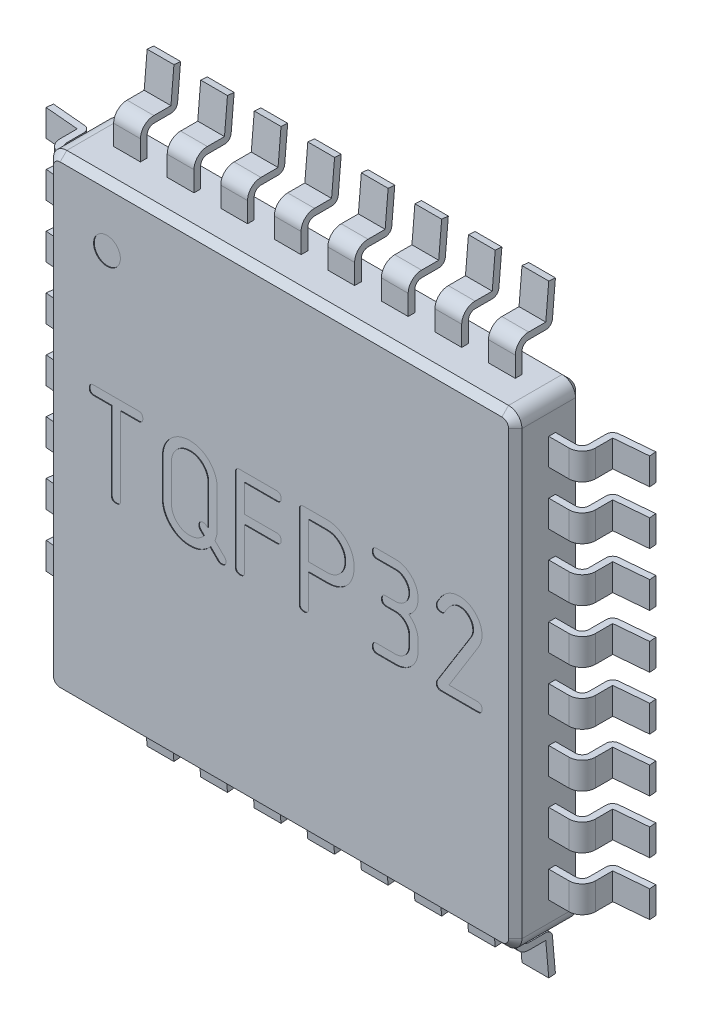
from build123d import *

# Parameters (mm, degrees)
EXTRUDE_1_DEPTH                  = 1
CHAMFER_1_SIZE                   = 0.1
EXTRUDE_2_DEPTH                  = 0.2
PATTERN_LINEAR_1_COUNT           = 8
PATTERN_LINEAR_1_PITCH           = 0.8
PATTERN_CIRCULAR_1_COUNT         = 4
PATTERN_CIRCULAR_1_COPY_1_DEPTH  = 0.2
PATTERN_CIRCULAR_1_COPY_2_DEPTH  = 0.2
PATTERN_CIRCULAR_1_COPY_3_DEPTH  = 0.2
PATTERN_CIRCULAR_1_COPY_4_DEPTH  = 0.2
PATTERN_CIRCULAR_1_COPY_5_DEPTH  = 0.2
PATTERN_CIRCULAR_1_COPY_6_DEPTH  = 0.2
PATTERN_CIRCULAR_1_COPY_7_DEPTH  = 0.2
PATTERN_CIRCULAR_1_COPY_8_DEPTH  = 0.2
PATTERN_CIRCULAR_1_COPY_9_DEPTH  = 0.2
PATTERN_CIRCULAR_1_COPY_10_DEPTH = 0.2
PATTERN_CIRCULAR_1_COPY_11_DEPTH = 0.2
PATTERN_CIRCULAR_1_COPY_12_DEPTH = 0.2
PATTERN_CIRCULAR_1_COPY_13_DEPTH = 0.2
PATTERN_CIRCULAR_1_COPY_14_DEPTH = 0.2
PATTERN_CIRCULAR_1_COPY_15_DEPTH = 0.2
PATTERN_CIRCULAR_1_COPY_16_DEPTH = 0.2
PATTERN_CIRCULAR_1_COPY_17_DEPTH = 0.2
PATTERN_CIRCULAR_1_COPY_18_DEPTH = 0.2
PATTERN_CIRCULAR_1_COPY_19_DEPTH = 0.2
PATTERN_CIRCULAR_1_COPY_20_DEPTH = 0.2
PATTERN_CIRCULAR_1_COPY_21_DEPTH = 0.2
SKETCH_4_R                       = 0.2
CUT_EXTRUDE_1_DEPTH              = 0.01


with BuildPart() as part:
    # Эскиз2 → Бобышка-Вытянуть1 (new body)
    with BuildSketch(Plane.XY.offset(0.1)):
        with BuildLine():
            Line((-3.3, 3.5), (3.3, 3.5))
            ThreePointArc((3.3, 3.5), (3.441421356, 3.441421356), (3.5, 3.3))
            Line((3.5, 3.3), (3.5, -3.3))
            ThreePointArc((3.5, -3.3), (3.441421356, -3.441421356), (3.3, -3.5))
            Line((3.3, -3.5), (-3.3, -3.5))
            ThreePointArc((-3.3, -3.5), (-3.441421356, -3.441421356), (-3.5, -3.3))
            Line((-3.5, -3.3), (-3.5, 3.3))
            ThreePointArc((-3.5, 3.3), (-3.441421356, 3.441421356), (-3.3, 3.5))
        make_face()
    extrude(amount=EXTRUDE_1_DEPTH)

    # Фаска1
    chamfer_1_edges = [part.edges().sort_by_distance(p)[0] for p in [
        (0, 3.5, 0.1),
        (-3.441421356, 3.441421356, 0.1),
        (3.441421356, 3.441421356, 0.1),
        (-3.5, 0, 0.1),
        (3.5, 0, 0.1),
        (-3.441421356, -3.441421356, 0.1),
        (3.441421356, -3.441421356, 0.1),
        (0, -3.5, 0.1),
        (0, 3.5, 1.1),
        (-3.441421356, 3.441421356, 1.1),
        (3.441421356, 3.441421356, 1.1),
        (-3.5, 0, 1.1),
        (3.5, 0, 1.1),
        (-3.441421356, -3.441421356, 1.1),
        (3.441421356, -3.441421356, 1.1),
        (0, -3.5, 1.1),
    ]]
    chamfer(chamfer_1_edges, length=CHAMFER_1_SIZE)

    # Эскиз3 → Бобышка-Вытянуть2 (add, symmetric)
    with BuildSketch(Plane(origin=(0, 2.8, 0), x_dir=(-1, 0, 0), z_dir=(0, 1, 0))):
        with BuildLine():
            Line((3.5, 0.5), (3.8, 0.5))
            ThreePointArc((3.8, 0.5), (3.870710678, 0.470710678), (3.9, 0.4))
            Line((3.9, 0.4), (3.9, 0.144126316))
            ThreePointArc((3.9, 0.144126316), (3.926272266, 0.076567295), (3.991284426, 0.044506846))
            Line((3.991284426, 0.044506846), (4.5, 0))
            Line((4.5, 0), (4.508715574, 0.09961947))
            Line((4.508715574, 0.09961947), (4, 0.144126316))
            Line((4, 0.144126316), (4, 0.4))
            ThreePointArc((4, 0.4), (3.941421356, 0.541421356), (3.8, 0.6))
            Line((3.8, 0.6), (3.5, 0.6))
            Line((3.5, 0.6), (3.5, 0.5))
        make_face()
    extrude_2 = extrude(amount=EXTRUDE_2_DEPTH, both=True)

    # Линейный массив1: Бобышка-Вытянуть2 ×8
    with Locations(*[(0, -i * PATTERN_LINEAR_1_PITCH, 0) for i in range(1, PATTERN_LINEAR_1_COUNT)]):
        add(extrude_2)

    # Круговой массив1: Бобышка-Вытянуть2 ×4 about axis
    pattern_circular_1_axis = Axis((0, 0, -0.055), (0, 0, 1))
    for i in range(1, PATTERN_CIRCULAR_1_COUNT):
        add(extrude_2.rotate(pattern_circular_1_axis, i * 360 / PATTERN_CIRCULAR_1_COUNT))

    # Круговой массив1 copy 1 sketch → Круговой массив1 copy 1 (add, symmetric)
    with BuildSketch(Plane(origin=(-2, 0, 0), x_dir=(0, -1, 0), z_dir=(-1, 0, 0))):
        with BuildLine():
            Line((3.5, 0.5), (3.8, 0.5))
            ThreePointArc((3.8, 0.5), (3.870710678, 0.470710678), (3.9, 0.4))
            Line((3.9, 0.4), (3.9, 0.144126316))
            ThreePointArc((3.9, 0.144126316), (3.926272266, 0.076567295), (3.991284426, 0.044506846))
            Line((3.991284426, 0.044506846), (4.5, 0))
            Line((4.5, 0), (4.508715574, 0.09961947))
            Line((4.508715574, 0.09961947), (4, 0.144126316))
            Line((4, 0.144126316), (4, 0.4))
            ThreePointArc((4, 0.4), (3.941421356, 0.541421356), (3.8, 0.6))
            Line((3.8, 0.6), (3.5, 0.6))
            Line((3.5, 0.6), (3.5, 0.5))
        make_face()
    extrude(amount=PATTERN_CIRCULAR_1_COPY_1_DEPTH, both=True)

    # Круговой массив1 copy 2 sketch → Круговой массив1 copy 2 (add, symmetric)
    with BuildSketch(Plane.XZ.offset(2)):
        with BuildLine():
            Line((3.5, 0.5), (3.8, 0.5))
            ThreePointArc((3.8, 0.5), (3.870710678, 0.470710678), (3.9, 0.4))
            Line((3.9, 0.4), (3.9, 0.144126316))
            ThreePointArc((3.9, 0.144126316), (3.926272266, 0.076567295), (3.991284426, 0.044506846))
            Line((3.991284426, 0.044506846), (4.5, 0))
            Line((4.5, 0), (4.508715574, 0.09961947))
            Line((4.508715574, 0.09961947), (4, 0.144126316))
            Line((4, 0.144126316), (4, 0.4))
            ThreePointArc((4, 0.4), (3.941421356, 0.541421356), (3.8, 0.6))
            Line((3.8, 0.6), (3.5, 0.6))
            Line((3.5, 0.6), (3.5, 0.5))
        make_face()
    extrude(amount=PATTERN_CIRCULAR_1_COPY_2_DEPTH, both=True)

    # Круговой массив1 copy 3 sketch → Круговой массив1 copy 3 (add, symmetric)
    with BuildSketch(Plane.YZ.offset(2)):
        with BuildLine():
            Line((3.5, 0.5), (3.8, 0.5))
            ThreePointArc((3.8, 0.5), (3.870710678, 0.470710678), (3.9, 0.4))
            Line((3.9, 0.4), (3.9, 0.144126316))
            ThreePointArc((3.9, 0.144126316), (3.926272266, 0.076567295), (3.991284426, 0.044506846))
            Line((3.991284426, 0.044506846), (4.5, 0))
            Line((4.5, 0), (4.508715574, 0.09961947))
            Line((4.508715574, 0.09961947), (4, 0.144126316))
            Line((4, 0.144126316), (4, 0.4))
            ThreePointArc((4, 0.4), (3.941421356, 0.541421356), (3.8, 0.6))
            Line((3.8, 0.6), (3.5, 0.6))
            Line((3.5, 0.6), (3.5, 0.5))
        make_face()
    extrude(amount=PATTERN_CIRCULAR_1_COPY_3_DEPTH, both=True)

    # Круговой массив1 copy 4 sketch → Круговой массив1 copy 4 (add, symmetric)
    with BuildSketch(Plane(origin=(-1.2, 0, 0), x_dir=(0, -1, 0), z_dir=(-1, 0, 0))):
        with BuildLine():
            Line((3.5, 0.5), (3.8, 0.5))
            ThreePointArc((3.8, 0.5), (3.870710678, 0.470710678), (3.9, 0.4))
            Line((3.9, 0.4), (3.9, 0.144126316))
            ThreePointArc((3.9, 0.144126316), (3.926272266, 0.076567295), (3.991284426, 0.044506846))
            Line((3.991284426, 0.044506846), (4.5, 0))
            Line((4.5, 0), (4.508715574, 0.09961947))
            Line((4.508715574, 0.09961947), (4, 0.144126316))
            Line((4, 0.144126316), (4, 0.4))
            ThreePointArc((4, 0.4), (3.941421356, 0.541421356), (3.8, 0.6))
            Line((3.8, 0.6), (3.5, 0.6))
            Line((3.5, 0.6), (3.5, 0.5))
        make_face()
    extrude(amount=PATTERN_CIRCULAR_1_COPY_4_DEPTH, both=True)

    # Круговой массив1 copy 5 sketch → Круговой массив1 copy 5 (add, symmetric)
    with BuildSketch(Plane.XZ.offset(1.2)):
        with BuildLine():
            Line((3.5, 0.5), (3.8, 0.5))
            ThreePointArc((3.8, 0.5), (3.870710678, 0.470710678), (3.9, 0.4))
            Line((3.9, 0.4), (3.9, 0.144126316))
            ThreePointArc((3.9, 0.144126316), (3.926272266, 0.076567295), (3.991284426, 0.044506846))
            Line((3.991284426, 0.044506846), (4.5, 0))
            Line((4.5, 0), (4.508715574, 0.09961947))
            Line((4.508715574, 0.09961947), (4, 0.144126316))
            Line((4, 0.144126316), (4, 0.4))
            ThreePointArc((4, 0.4), (3.941421356, 0.541421356), (3.8, 0.6))
            Line((3.8, 0.6), (3.5, 0.6))
            Line((3.5, 0.6), (3.5, 0.5))
        make_face()
    extrude(amount=PATTERN_CIRCULAR_1_COPY_5_DEPTH, both=True)

    # Круговой массив1 copy 6 sketch → Круговой массив1 copy 6 (add, symmetric)
    with BuildSketch(Plane.YZ.offset(1.2)):
        with BuildLine():
            Line((3.5, 0.5), (3.8, 0.5))
            ThreePointArc((3.8, 0.5), (3.870710678, 0.470710678), (3.9, 0.4))
            Line((3.9, 0.4), (3.9, 0.144126316))
            ThreePointArc((3.9, 0.144126316), (3.926272266, 0.076567295), (3.991284426, 0.044506846))
            Line((3.991284426, 0.044506846), (4.5, 0))
            Line((4.5, 0), (4.508715574, 0.09961947))
            Line((4.508715574, 0.09961947), (4, 0.144126316))
            Line((4, 0.144126316), (4, 0.4))
            ThreePointArc((4, 0.4), (3.941421356, 0.541421356), (3.8, 0.6))
            Line((3.8, 0.6), (3.5, 0.6))
            Line((3.5, 0.6), (3.5, 0.5))
        make_face()
    extrude(amount=PATTERN_CIRCULAR_1_COPY_6_DEPTH, both=True)

    # Круговой массив1 copy 7 sketch → Круговой массив1 copy 7 (add, symmetric)
    with BuildSketch(Plane(origin=(-0.4, 0, 0), x_dir=(0, -1, 0), z_dir=(-1, 0, 0))):
        with BuildLine():
            Line((3.5, 0.5), (3.8, 0.5))
            ThreePointArc((3.8, 0.5), (3.870710678, 0.470710678), (3.9, 0.4))
            Line((3.9, 0.4), (3.9, 0.144126316))
            ThreePointArc((3.9, 0.144126316), (3.926272266, 0.076567295), (3.991284426, 0.044506846))
            Line((3.991284426, 0.044506846), (4.5, 0))
            Line((4.5, 0), (4.508715574, 0.09961947))
            Line((4.508715574, 0.09961947), (4, 0.144126316))
            Line((4, 0.144126316), (4, 0.4))
            ThreePointArc((4, 0.4), (3.941421356, 0.541421356), (3.8, 0.6))
            Line((3.8, 0.6), (3.5, 0.6))
            Line((3.5, 0.6), (3.5, 0.5))
        make_face()
    extrude(amount=PATTERN_CIRCULAR_1_COPY_7_DEPTH, both=True)

    # Круговой массив1 copy 8 sketch → Круговой массив1 copy 8 (add, symmetric)
    with BuildSketch(Plane.XZ.offset(0.4)):
        with BuildLine():
            Line((3.5, 0.5), (3.8, 0.5))
            ThreePointArc((3.8, 0.5), (3.870710678, 0.470710678), (3.9, 0.4))
            Line((3.9, 0.4), (3.9, 0.144126316))
            ThreePointArc((3.9, 0.144126316), (3.926272266, 0.076567295), (3.991284426, 0.044506846))
            Line((3.991284426, 0.044506846), (4.5, 0))
            Line((4.5, 0), (4.508715574, 0.09961947))
            Line((4.508715574, 0.09961947), (4, 0.144126316))
            Line((4, 0.144126316), (4, 0.4))
            ThreePointArc((4, 0.4), (3.941421356, 0.541421356), (3.8, 0.6))
            Line((3.8, 0.6), (3.5, 0.6))
            Line((3.5, 0.6), (3.5, 0.5))
        make_face()
    extrude(amount=PATTERN_CIRCULAR_1_COPY_8_DEPTH, both=True)

    # Круговой массив1 copy 9 sketch → Круговой массив1 copy 9 (add, symmetric)
    with BuildSketch(Plane.YZ.offset(0.4)):
        with BuildLine():
            Line((3.5, 0.5), (3.8, 0.5))
            ThreePointArc((3.8, 0.5), (3.870710678, 0.470710678), (3.9, 0.4))
            Line((3.9, 0.4), (3.9, 0.144126316))
            ThreePointArc((3.9, 0.144126316), (3.926272266, 0.076567295), (3.991284426, 0.044506846))
            Line((3.991284426, 0.044506846), (4.5, 0))
            Line((4.5, 0), (4.508715574, 0.09961947))
            Line((4.508715574, 0.09961947), (4, 0.144126316))
            Line((4, 0.144126316), (4, 0.4))
            ThreePointArc((4, 0.4), (3.941421356, 0.541421356), (3.8, 0.6))
            Line((3.8, 0.6), (3.5, 0.6))
            Line((3.5, 0.6), (3.5, 0.5))
        make_face()
    extrude(amount=PATTERN_CIRCULAR_1_COPY_9_DEPTH, both=True)

    # Круговой массив1 copy 10 sketch → Круговой массив1 copy 10 (add, symmetric)
    with BuildSketch(Plane(origin=(0.4, 0, 0), x_dir=(0, -1, 0), z_dir=(-1, 0, 0))):
        with BuildLine():
            Line((3.5, 0.5), (3.8, 0.5))
            ThreePointArc((3.8, 0.5), (3.870710678, 0.470710678), (3.9, 0.4))
            Line((3.9, 0.4), (3.9, 0.144126316))
            ThreePointArc((3.9, 0.144126316), (3.926272266, 0.076567295), (3.991284426, 0.044506846))
            Line((3.991284426, 0.044506846), (4.5, 0))
            Line((4.5, 0), (4.508715574, 0.09961947))
            Line((4.508715574, 0.09961947), (4, 0.144126316))
            Line((4, 0.144126316), (4, 0.4))
            ThreePointArc((4, 0.4), (3.941421356, 0.541421356), (3.8, 0.6))
            Line((3.8, 0.6), (3.5, 0.6))
            Line((3.5, 0.6), (3.5, 0.5))
        make_face()
    extrude(amount=PATTERN_CIRCULAR_1_COPY_10_DEPTH, both=True)

    # Круговой массив1 copy 11 sketch → Круговой массив1 copy 11 (add, symmetric)
    with BuildSketch(Plane.XZ.offset(-0.4)):
        with BuildLine():
            Line((3.5, 0.5), (3.8, 0.5))
            ThreePointArc((3.8, 0.5), (3.870710678, 0.470710678), (3.9, 0.4))
            Line((3.9, 0.4), (3.9, 0.144126316))
            ThreePointArc((3.9, 0.144126316), (3.926272266, 0.076567295), (3.991284426, 0.044506846))
            Line((3.991284426, 0.044506846), (4.5, 0))
            Line((4.5, 0), (4.508715574, 0.09961947))
            Line((4.508715574, 0.09961947), (4, 0.144126316))
            Line((4, 0.144126316), (4, 0.4))
            ThreePointArc((4, 0.4), (3.941421356, 0.541421356), (3.8, 0.6))
            Line((3.8, 0.6), (3.5, 0.6))
            Line((3.5, 0.6), (3.5, 0.5))
        make_face()
    extrude(amount=PATTERN_CIRCULAR_1_COPY_11_DEPTH, both=True)

    # Круговой массив1 copy 12 sketch → Круговой массив1 copy 12 (add, symmetric)
    with BuildSketch(Plane.YZ.offset(-0.4)):
        with BuildLine():
            Line((3.5, 0.5), (3.8, 0.5))
            ThreePointArc((3.8, 0.5), (3.870710678, 0.470710678), (3.9, 0.4))
            Line((3.9, 0.4), (3.9, 0.144126316))
            ThreePointArc((3.9, 0.144126316), (3.926272266, 0.076567295), (3.991284426, 0.044506846))
            Line((3.991284426, 0.044506846), (4.5, 0))
            Line((4.5, 0), (4.508715574, 0.09961947))
            Line((4.508715574, 0.09961947), (4, 0.144126316))
            Line((4, 0.144126316), (4, 0.4))
            ThreePointArc((4, 0.4), (3.941421356, 0.541421356), (3.8, 0.6))
            Line((3.8, 0.6), (3.5, 0.6))
            Line((3.5, 0.6), (3.5, 0.5))
        make_face()
    extrude(amount=PATTERN_CIRCULAR_1_COPY_12_DEPTH, both=True)

    # Круговой массив1 copy 13 sketch → Круговой массив1 copy 13 (add, symmetric)
    with BuildSketch(Plane(origin=(1.2, 0, 0), x_dir=(0, -1, 0), z_dir=(-1, 0, 0))):
        with BuildLine():
            Line((3.5, 0.5), (3.8, 0.5))
            ThreePointArc((3.8, 0.5), (3.870710678, 0.470710678), (3.9, 0.4))
            Line((3.9, 0.4), (3.9, 0.144126316))
            ThreePointArc((3.9, 0.144126316), (3.926272266, 0.076567295), (3.991284426, 0.044506846))
            Line((3.991284426, 0.044506846), (4.5, 0))
            Line((4.5, 0), (4.508715574, 0.09961947))
            Line((4.508715574, 0.09961947), (4, 0.144126316))
            Line((4, 0.144126316), (4, 0.4))
            ThreePointArc((4, 0.4), (3.941421356, 0.541421356), (3.8, 0.6))
            Line((3.8, 0.6), (3.5, 0.6))
            Line((3.5, 0.6), (3.5, 0.5))
        make_face()
    extrude(amount=PATTERN_CIRCULAR_1_COPY_13_DEPTH, both=True)

    # Круговой массив1 copy 14 sketch → Круговой массив1 copy 14 (add, symmetric)
    with BuildSketch(Plane.XZ.offset(-1.2)):
        with BuildLine():
            Line((3.5, 0.5), (3.8, 0.5))
            ThreePointArc((3.8, 0.5), (3.870710678, 0.470710678), (3.9, 0.4))
            Line((3.9, 0.4), (3.9, 0.144126316))
            ThreePointArc((3.9, 0.144126316), (3.926272266, 0.076567295), (3.991284426, 0.044506846))
            Line((3.991284426, 0.044506846), (4.5, 0))
            Line((4.5, 0), (4.508715574, 0.09961947))
            Line((4.508715574, 0.09961947), (4, 0.144126316))
            Line((4, 0.144126316), (4, 0.4))
            ThreePointArc((4, 0.4), (3.941421356, 0.541421356), (3.8, 0.6))
            Line((3.8, 0.6), (3.5, 0.6))
            Line((3.5, 0.6), (3.5, 0.5))
        make_face()
    extrude(amount=PATTERN_CIRCULAR_1_COPY_14_DEPTH, both=True)

    # Круговой массив1 copy 15 sketch → Круговой массив1 copy 15 (add, symmetric)
    with BuildSketch(Plane.YZ.offset(-1.2)):
        with BuildLine():
            Line((3.5, 0.5), (3.8, 0.5))
            ThreePointArc((3.8, 0.5), (3.870710678, 0.470710678), (3.9, 0.4))
            Line((3.9, 0.4), (3.9, 0.144126316))
            ThreePointArc((3.9, 0.144126316), (3.926272266, 0.076567295), (3.991284426, 0.044506846))
            Line((3.991284426, 0.044506846), (4.5, 0))
            Line((4.5, 0), (4.508715574, 0.09961947))
            Line((4.508715574, 0.09961947), (4, 0.144126316))
            Line((4, 0.144126316), (4, 0.4))
            ThreePointArc((4, 0.4), (3.941421356, 0.541421356), (3.8, 0.6))
            Line((3.8, 0.6), (3.5, 0.6))
            Line((3.5, 0.6), (3.5, 0.5))
        make_face()
    extrude(amount=PATTERN_CIRCULAR_1_COPY_15_DEPTH, both=True)

    # Круговой массив1 copy 16 sketch → Круговой массив1 copy 16 (add, symmetric)
    with BuildSketch(Plane(origin=(2, 0, 0), x_dir=(0, -1, 0), z_dir=(-1, 0, 0))):
        with BuildLine():
            Line((3.5, 0.5), (3.8, 0.5))
            ThreePointArc((3.8, 0.5), (3.870710678, 0.470710678), (3.9, 0.4))
            Line((3.9, 0.4), (3.9, 0.144126316))
            ThreePointArc((3.9, 0.144126316), (3.926272266, 0.076567295), (3.991284426, 0.044506846))
            Line((3.991284426, 0.044506846), (4.5, 0))
            Line((4.5, 0), (4.508715574, 0.09961947))
            Line((4.508715574, 0.09961947), (4, 0.144126316))
            Line((4, 0.144126316), (4, 0.4))
            ThreePointArc((4, 0.4), (3.941421356, 0.541421356), (3.8, 0.6))
            Line((3.8, 0.6), (3.5, 0.6))
            Line((3.5, 0.6), (3.5, 0.5))
        make_face()
    extrude(amount=PATTERN_CIRCULAR_1_COPY_16_DEPTH, both=True)

    # Круговой массив1 copy 17 sketch → Круговой массив1 copy 17 (add, symmetric)
    with BuildSketch(Plane.XZ.offset(-2)):
        with BuildLine():
            Line((3.5, 0.5), (3.8, 0.5))
            ThreePointArc((3.8, 0.5), (3.870710678, 0.470710678), (3.9, 0.4))
            Line((3.9, 0.4), (3.9, 0.144126316))
            ThreePointArc((3.9, 0.144126316), (3.926272266, 0.076567295), (3.991284426, 0.044506846))
            Line((3.991284426, 0.044506846), (4.5, 0))
            Line((4.5, 0), (4.508715574, 0.09961947))
            Line((4.508715574, 0.09961947), (4, 0.144126316))
            Line((4, 0.144126316), (4, 0.4))
            ThreePointArc((4, 0.4), (3.941421356, 0.541421356), (3.8, 0.6))
            Line((3.8, 0.6), (3.5, 0.6))
            Line((3.5, 0.6), (3.5, 0.5))
        make_face()
    extrude(amount=PATTERN_CIRCULAR_1_COPY_17_DEPTH, both=True)

    # Круговой массив1 copy 18 sketch → Круговой массив1 copy 18 (add, symmetric)
    with BuildSketch(Plane.YZ.offset(-2)):
        with BuildLine():
            Line((3.5, 0.5), (3.8, 0.5))
            ThreePointArc((3.8, 0.5), (3.870710678, 0.470710678), (3.9, 0.4))
            Line((3.9, 0.4), (3.9, 0.144126316))
            ThreePointArc((3.9, 0.144126316), (3.926272266, 0.076567295), (3.991284426, 0.044506846))
            Line((3.991284426, 0.044506846), (4.5, 0))
            Line((4.5, 0), (4.508715574, 0.09961947))
            Line((4.508715574, 0.09961947), (4, 0.144126316))
            Line((4, 0.144126316), (4, 0.4))
            ThreePointArc((4, 0.4), (3.941421356, 0.541421356), (3.8, 0.6))
            Line((3.8, 0.6), (3.5, 0.6))
            Line((3.5, 0.6), (3.5, 0.5))
        make_face()
    extrude(amount=PATTERN_CIRCULAR_1_COPY_18_DEPTH, both=True)

    # Круговой массив1 copy 19 sketch → Круговой массив1 copy 19 (add, symmetric)
    with BuildSketch(Plane(origin=(2.8, 0, 0), x_dir=(0, -1, 0), z_dir=(-1, 0, 0))):
        with BuildLine():
            Line((3.5, 0.5), (3.8, 0.5))
            ThreePointArc((3.8, 0.5), (3.870710678, 0.470710678), (3.9, 0.4))
            Line((3.9, 0.4), (3.9, 0.144126316))
            ThreePointArc((3.9, 0.144126316), (3.926272266, 0.076567295), (3.991284426, 0.044506846))
            Line((3.991284426, 0.044506846), (4.5, 0))
            Line((4.5, 0), (4.508715574, 0.09961947))
            Line((4.508715574, 0.09961947), (4, 0.144126316))
            Line((4, 0.144126316), (4, 0.4))
            ThreePointArc((4, 0.4), (3.941421356, 0.541421356), (3.8, 0.6))
            Line((3.8, 0.6), (3.5, 0.6))
            Line((3.5, 0.6), (3.5, 0.5))
        make_face()
    extrude(amount=PATTERN_CIRCULAR_1_COPY_19_DEPTH, both=True)

    # Круговой массив1 copy 20 sketch → Круговой массив1 copy 20 (add, symmetric)
    with BuildSketch(Plane.XZ.offset(-2.8)):
        with BuildLine():
            Line((3.5, 0.5), (3.8, 0.5))
            ThreePointArc((3.8, 0.5), (3.870710678, 0.470710678), (3.9, 0.4))
            Line((3.9, 0.4), (3.9, 0.144126316))
            ThreePointArc((3.9, 0.144126316), (3.926272266, 0.076567295), (3.991284426, 0.044506846))
            Line((3.991284426, 0.044506846), (4.5, 0))
            Line((4.5, 0), (4.508715574, 0.09961947))
            Line((4.508715574, 0.09961947), (4, 0.144126316))
            Line((4, 0.144126316), (4, 0.4))
            ThreePointArc((4, 0.4), (3.941421356, 0.541421356), (3.8, 0.6))
            Line((3.8, 0.6), (3.5, 0.6))
            Line((3.5, 0.6), (3.5, 0.5))
        make_face()
    extrude(amount=PATTERN_CIRCULAR_1_COPY_20_DEPTH, both=True)

    # Круговой массив1 copy 21 sketch → Круговой массив1 copy 21 (add, symmetric)
    with BuildSketch(Plane.YZ.offset(-2.8)):
        with BuildLine():
            Line((3.5, 0.5), (3.8, 0.5))
            ThreePointArc((3.8, 0.5), (3.870710678, 0.470710678), (3.9, 0.4))
            Line((3.9, 0.4), (3.9, 0.144126316))
            ThreePointArc((3.9, 0.144126316), (3.926272266, 0.076567295), (3.991284426, 0.044506846))
            Line((3.991284426, 0.044506846), (4.5, 0))
            Line((4.5, 0), (4.508715574, 0.09961947))
            Line((4.508715574, 0.09961947), (4, 0.144126316))
            Line((4, 0.144126316), (4, 0.4))
            ThreePointArc((4, 0.4), (3.941421356, 0.541421356), (3.8, 0.6))
            Line((3.8, 0.6), (3.5, 0.6))
            Line((3.5, 0.6), (3.5, 0.5))
        make_face()
    extrude(amount=PATTERN_CIRCULAR_1_COPY_21_DEPTH, both=True)

    # Эскиз4 → Вырез-Вытянуть1 (cut)
    # profile 1 of 7: a face of its own
    with BuildSketch(Plane.XY.offset(1.1)):
        with Locations((-2.6, 2.6)):
            Circle(SKETCH_4_R)
    # profile 2 of 7: a face of its own
    with BuildSketch(Plane.XY.offset(1.1)):
        with BuildLine():
            add(Edge.make_bspline(
                [(-2.863574219, 0.696044922), (-2.863499556, 0.701454201), (-2.863359739, 0.711583935), (-2.859706908, 0.725607276), (-2.854827007, 0.737767671), (-2.847088481, 0.747551936), (-2.837604046, 0.755357852), (-2.825690402, 0.760522822), (-2.812002269, 0.763970293), (-2.802085023, 0.764158899), (-2.796883937, 0.764257812)],
                knots=[0, 0, 0, 0, 1.182571124, 2.214551965, 3.162306919, 4.035667748, 4.922840852, 5.829928053, 6.861908894, 8, 8, 8, 8], degree=3))
            Line((-2.796883937, 0.764257812), (-2.13119921, 0.764257812))
            add(Edge.make_bspline(
                [(-2.13119921, 0.764257812), (-2.125998125, 0.764158899), (-2.116080879, 0.763970293), (-2.102392745, 0.760522822), (-2.090479101, 0.755357852), (-2.080994666, 0.747551936), (-2.07325614, 0.737767671), (-2.068376239, 0.725607276), (-2.064723409, 0.711583935), (-2.064583591, 0.701454201), (-2.064508929, 0.696044922)],
                knots=[0, 0, 0, 0, 1.138091106, 2.170071947, 3.077159148, 3.964332252, 4.837693081, 5.785448035, 6.817428876, 8, 8, 8, 8], degree=3))
            add(Edge.make_bspline(
                [(-2.064508929, 0.696044922), (-2.06461301, 0.690746895), (-2.064811602, 0.680638014), (-2.068199576, 0.66659925), (-2.073509728, 0.654673554), (-2.080438751, 0.644415267), (-2.090461836, 0.637097944), (-2.102079332, 0.631480892), (-2.115944173, 0.628591162), (-2.125707207, 0.628095432), (-2.130894688, 0.627832031)],
                knots=[0, 0, 0, 0, 1.164100439, 2.221157785, 3.151547364, 4.032294591, 4.90849306, 5.848230839, 6.856681008, 8, 8, 8, 8], degree=3))
            Line((-2.130894688, 0.627832031), (-2.395828683, 0.627832031))
            Line((-2.395828683, 0.627832031), (-2.395828683, -0.531787109))
            add(Edge.make_bspline(
                [(-2.395828683, -0.531787109), (-2.395928294, -0.537088561), (-2.396118356, -0.547203977), (-2.399563506, -0.561198939), (-2.404736518, -0.573379218), (-2.412419091, -0.583224228), (-2.422407957, -0.590852025), (-2.434345958, -0.596326841), (-2.448578254, -0.599267683), (-2.458648587, -0.599744597), (-2.464041574, -0.6)],
                knots=[0, 0, 0, 0, 1.147825403, 2.190104258, 3.107486261, 4.002358969, 4.866307497, 5.812869616, 6.828721528, 8, 8, 8, 8], degree=3))
            add(Edge.make_bspline(
                [(-2.464041574, -0.6), (-2.469325484, -0.599719929), (-2.479378707, -0.599187063), (-2.493606427, -0.596480885), (-2.505426383, -0.59064299), (-2.515707934, -0.58345347), (-2.522897454, -0.573171919), (-2.528735349, -0.561351963), (-2.531441527, -0.547124243), (-2.531974393, -0.537071019), (-2.532254464, -0.531787109)],
                knots=[0, 0, 0, 0, 1.150813752, 2.189550435, 3.117366144, 4, 4.882633856, 5.810449565, 6.849186248, 8, 8, 8, 8], degree=3))
            Line((-2.532254464, -0.531787109), (-2.532254464, 0.627832031))
            Line((-2.532254464, 0.627832031), (-2.797188459, 0.627832031))
            add(Edge.make_bspline(
                [(-2.797188459, 0.627832031), (-2.802378118, 0.628092994), (-2.81214525, 0.628584134), (-2.825982734, 0.631504498), (-2.837619773, 0.636983845), (-2.847322918, 0.644622303), (-2.854632263, 0.654550842), (-2.859857597, 0.666620355), (-2.863279189, 0.680631803), (-2.863472766, 0.69074476), (-2.863574219, 0.696044922)],
                knots=[0, 0, 0, 0, 1.14393887, 2.152935795, 3.093183076, 3.952283899, 4.846743947, 5.77763796, 6.835268415, 8, 8, 8, 8], degree=3))
        make_face()
    # profile 3 of 7: a face of its own
    with BuildSketch(Plane.XY.offset(1.1)):
        with BuildLine():
            add(Edge.make_bspline(
                [(-1.060195923, -0.461138044), (-1.070197696, -0.472253357), (-1.089843272, -0.49408616), (-1.123271134, -0.522099026), (-1.158231905, -0.546481853), (-1.195758043, -0.565990186), (-1.235136658, -0.581394886), (-1.276793706, -0.591886148), (-1.320322842, -0.598925758), (-1.350173713, -0.599638296), (-1.3653268, -0.6)],
                knots=[0, 0, 0, 0, 1.034406248, 2.031790478, 3.012635843, 3.981159625, 4.953782538, 5.93422472, 6.951358134, 8, 8, 8, 8], degree=3))
            add(Edge.make_bspline(
                [(-1.3653268, -0.6), (-1.379156527, -0.599702973), (-1.406333311, -0.599119286), (-1.446242958, -0.592888213), (-1.484787025, -0.58400025), (-1.52181612, -0.570898562), (-1.556950393, -0.553444963), (-1.591030394, -0.533252296), (-1.623043289, -0.508433173), (-1.653560646, -0.480794077), (-1.681358345, -0.450345094), (-1.705548371, -0.417854067), (-1.726187954, -0.383854704), (-1.742860438, -0.34817081), (-1.756147532, -0.310981637), (-1.765543444, -0.272313709), (-1.771159889, -0.231998845), (-1.771827891, -0.204647254), (-1.772167969, -0.190722656)],
                knots=[0, 0, 0, 0, 1.033312615, 2.030561505, 3.013700211, 3.988422536, 4.959324787, 5.943459254, 6.945434469, 7.982448381, 9.019462293, 10.022931451, 11.007065918, 11.988386222, 12.963108547, 13.955405407, 14.959104204, 16, 16, 16, 16], degree=3))
            Line((-1.772167969, -0.190722656), (-1.772167969, 0.354980469))
            add(Edge.make_bspline(
                [(-1.772167969, 0.354980469), (-1.771871855, 0.368911895), (-1.771289907, 0.396291105), (-1.765044547, 0.436498851), (-1.756233107, 0.4752723), (-1.742980742, 0.512443171), (-1.725717057, 0.547774677), (-1.705313206, 0.581925923), (-1.680709523, 0.614197849), (-1.652958854, 0.644741217), (-1.622426554, 0.672520544), (-1.590041995, 0.697034679), (-1.556026417, 0.717951867), (-1.520404938, 0.734972783), (-1.4831919, 0.748341133), (-1.444406435, 0.757129436), (-1.404201935, 0.763381049), (-1.376822278, 0.763962136), (-1.362890625, 0.764257812)],
                knots=[0, 0, 0, 0, 1.037886018, 2.039740928, 3.027401155, 3.999305046, 4.97421019, 5.955499007, 6.96060772, 7.994623079, 9.028638438, 10.033747151, 11.018968421, 12.000694954, 12.972598845, 13.960259072, 14.962113982, 16, 16, 16, 16], degree=3))
            add(Edge.make_bspline(
                [(-1.362890625, 0.764257812), (-1.348961871, 0.76394563), (-1.321386839, 0.763327596), (-1.281042477, 0.757258971), (-1.242129955, 0.748197229), (-1.204881207, 0.735169331), (-1.169453951, 0.717692806), (-1.135099253, 0.697602947), (-1.103054632, 0.672676166), (-1.072501803, 0.645070659), (-1.044766058, 0.614498704), (-1.02018284, 0.582221352), (-0.999708241, 0.548155598), (-0.982765914, 0.512596211), (-0.969711542, 0.475311836), (-0.960188726, 0.436480643), (-0.95463108, 0.39594825), (-0.953956615, 0.368396503), (-0.953613281, 0.354371425)],
                knots=[0, 0, 0, 0, 1.036325472, 2.051634171, 3.03045615, 4.008022873, 4.981462168, 5.967753184, 6.965328966, 7.997789598, 9.030250231, 10.033847681, 11.013661049, 11.98383874, 12.961405463, 13.949345385, 14.956124537, 16, 16, 16, 16], degree=3))
            Line((-0.953613281, 0.354371425), (-0.953613281, -0.191940744))
            add(Edge.make_bspline(
                [(-0.953613281, -0.191940744), (-0.954044754, -0.20445193), (-0.95491266, -0.229618139), (-0.961354962, -0.267243131), (-0.971249545, -0.305089364), (-0.981147851, -0.329578004), (-0.986197117, -0.342070007)],
                knots=[0, 0, 0, 0, 0.970505138, 1.952167884, 2.955371787, 4, 4, 4, 4], degree=3))
            Line((-0.986197117, -0.342070007), (-0.845203509, -0.482759094))
            add(Edge.make_bspline(
                [(-0.845203509, -0.482759094), (-0.841843103, -0.486521727), (-0.83532734, -0.493817401), (-0.827628149, -0.506080737), (-0.823745773, -0.519483516), (-0.823026135, -0.528519545), (-0.822668893, -0.533005197)],
                knots=[0, 0, 0, 0, 1.071060325, 2.076765767, 3.045270919, 4, 4, 4, 4], degree=3))
            add(Edge.make_bspline(
                [(-0.822668893, -0.533005197), (-0.822745184, -0.538311598), (-0.822887906, -0.548238535), (-0.826511544, -0.561986621), (-0.831526274, -0.573844622), (-0.839069868, -0.583726459), (-0.849087887, -0.591054614), (-0.861063776, -0.596229641), (-0.874951532, -0.599739695), (-0.884970156, -0.59990991), (-0.89027274, -0.6)],
                knots=[0, 0, 0, 0, 1.162919306, 2.175528415, 3.104973992, 3.980283443, 4.873351745, 5.802797322, 6.837080694, 8, 8, 8, 8], degree=3))
            add(Edge.make_bspline(
                [(-0.89027274, -0.6), (-0.89528197, -0.599821462), (-0.904965954, -0.599476306), (-0.91866794, -0.595204019), (-0.931289792, -0.588857191), (-0.938212329, -0.582519396), (-0.94173693, -0.579292515)],
                knots=[0, 0, 0, 0, 1.051152796, 2.032117937, 2.998055438, 4, 4, 4, 4], degree=3))
            Line((-0.94173693, -0.579292515), (-1.060195923, -0.461138044))
        make_face()
        with BuildLine():
            add(Edge.make_bspline(
                [(-1.154597691, -0.365213667), (-1.162288201, -0.357677112), (-1.177773766, -0.342501552), (-1.193551785, -0.327630273), (-1.201494053, -0.320144435)],
                knots=[0, 0, 0, 0, 0.993248859, 2, 2, 2, 2], degree=3))
            add(Edge.make_bspline(
                [(-1.201494053, -0.320144435), (-1.205354689, -0.315507826), (-1.212744509, -0.306632677), (-1.220109667, -0.291747292), (-1.225641164, -0.277288661), (-1.226194823, -0.267408426), (-1.226464844, -0.262589809)],
                knots=[0, 0, 0, 0, 1.126404379, 2.156102701, 3.100726277, 4, 4, 4, 4], degree=3))
            add(Edge.make_bspline(
                [(-1.226464844, -0.262589809), (-1.226197842, -0.257301285), (-1.225694841, -0.247338322), (-1.222862869, -0.233265863), (-1.217168596, -0.221374597), (-1.209587077, -0.211474332), (-1.199649215, -0.203750606), (-1.18742795, -0.198794327), (-1.173271431, -0.195237406), (-1.16304889, -0.195072938), (-1.157642909, -0.194985962)],
                knots=[0, 0, 0, 0, 1.14927305, 2.165096508, 3.091670063, 3.986517706, 4.850442035, 5.787956674, 6.830206335, 8, 8, 8, 8], degree=3))
            add(Edge.make_bspline(
                [(-1.157642909, -0.194985962), (-1.152606041, -0.195431414), (-1.141823553, -0.196385), (-1.125781325, -0.203823791), (-1.109151941, -0.21538455), (-1.098725197, -0.225465629), (-1.093084281, -0.230919538)],
                knots=[0, 0, 0, 0, 0.796498202, 1.705073476, 2.758434321, 4, 4, 4, 4], degree=3))
            add(Edge.make_bspline(
                [(-1.093084281, -0.230919538), (-1.092120599, -0.224638209), (-1.090169846, -0.211923101), (-1.090083004, -0.199058971), (-1.090039063, -0.192549787)],
                knots=[0, 0, 0, 0, 0.988010265, 2, 2, 2, 2], degree=3))
            Line((-1.090039063, -0.192549787), (-1.090039063, 0.354371425))
            add(Edge.make_bspline(
                [(-1.090039063, 0.354371425), (-1.090274995, 0.363820846), (-1.090738546, 0.382386662), (-1.094336895, 0.409682193), (-1.10101143, 0.435661237), (-1.109180161, 0.460786363), (-1.12097766, 0.48433988), (-1.134008315, 0.507362552), (-1.150569616, 0.528692408), (-1.168881557, 0.548988072), (-1.189171939, 0.567313994), (-1.210466488, 0.583762523), (-1.23327572, 0.596982272), (-1.256788146, 0.608677485), (-1.281903172, 0.61686329), (-1.307884975, 0.62353334), (-1.335078915, 0.627118934), (-1.353542854, 0.627592353), (-1.362890625, 0.627832031)],
                knots=[0, 0, 0, 0, 1.053369312, 2.069614645, 3.060402755, 4.040927392, 5.007642059, 5.991621439, 6.985184418, 8.010524553, 9.035864687, 10.029427666, 11.003663465, 11.970378132, 12.950902769, 13.941690878, 14.957936211, 16, 16, 16, 16], degree=3))
            add(Edge.make_bspline(
                [(-1.362890625, 0.627832031), (-1.372238543, 0.627592662), (-1.390702772, 0.627119853), (-1.417894594, 0.623529808), (-1.443884182, 0.616876117), (-1.469057887, 0.608601725), (-1.492750931, 0.597069935), (-1.515611686, 0.583749737), (-1.536923942, 0.567322995), (-1.557170563, 0.548964633), (-1.575597379, 0.528820737), (-1.591547741, 0.507192776), (-1.605376217, 0.484796435), (-1.61637279, 0.460910849), (-1.625298407, 0.436099025), (-1.631303407, 0.409922621), (-1.635066385, 0.382802552), (-1.635515044, 0.364331726), (-1.635742188, 0.354980469)],
                knots=[0, 0, 0, 0, 1.043079502, 2.060315384, 3.052069228, 4.033549595, 5.011428428, 5.986613828, 6.981145247, 8.007484794, 9.033824341, 10.021559559, 11.002582284, 11.965387447, 12.950586422, 13.939684616, 14.956920498, 16, 16, 16, 16], degree=3))
            Line((-1.635742188, 0.354980469), (-1.635742188, -0.190722656))
            add(Edge.make_bspline(
                [(-1.635742188, -0.190722656), (-1.63551295, -0.200073218), (-1.635060154, -0.218542668), (-1.631327332, -0.245672764), (-1.625219126, -0.271779832), (-1.616686284, -0.296784018), (-1.605739887, -0.320771743), (-1.591859011, -0.343245033), (-1.57590378, -0.364782694), (-1.557772934, -0.38497577), (-1.537930749, -0.403520261), (-1.516309282, -0.419365729), (-1.493930302, -0.433218763), (-1.470115239, -0.444136842), (-1.445540753, -0.453138711), (-1.419661527, -0.459133227), (-1.392745212, -0.462913752), (-1.374374034, -0.463351424), (-1.365022278, -0.463574219)],
                knots=[0, 0, 0, 0, 1.046826641, 2.067716821, 3.060368233, 4.045374452, 5.021948145, 6.006495077, 6.997778617, 8.020186662, 9.041836056, 10.033119595, 11.017666528, 11.983930454, 12.961958662, 13.943547904, 14.953173359, 16, 16, 16, 16], degree=3))
            add(Edge.make_bspline(
                [(-1.365022278, -0.463574219), (-1.354547751, -0.463300219), (-1.334002961, -0.462762794), (-1.30390771, -0.457975428), (-1.275167646, -0.450627345), (-1.248189899, -0.439274349), (-1.222269785, -0.425632203), (-1.198077045, -0.408488006), (-1.175077713, -0.388492209), (-1.161532446, -0.373096031), (-1.154597691, -0.365213667)],
                knots=[0, 0, 0, 0, 1.045093948, 2.049852409, 3.035622248, 3.999209887, 4.96498018, 5.954649543, 6.952844237, 8, 8, 8, 8], degree=3))
        make_face(mode=Mode.SUBTRACT)
    # profile 4 of 7: a face of its own
    with BuildSketch(Plane.XY.offset(1.1)):
        with BuildLine():
            Line((-0.680761719, -0.531787109), (-0.680761719, 0.696044922))
            add(Edge.make_bspline(
                [(-0.680761719, 0.696044922), (-0.680506316, 0.701437908), (-0.680029402, 0.711508242), (-0.67708856, 0.725740538), (-0.671613743, 0.737678539), (-0.663985947, 0.747667404), (-0.654140937, 0.755349977), (-0.641960657, 0.76052299), (-0.627965695, 0.763968139), (-0.61785028, 0.764158202), (-0.612548828, 0.764257812)],
                knots=[0, 0, 0, 0, 1.171278472, 2.187130384, 3.133692503, 3.997641031, 4.892513739, 5.809895742, 6.852174597, 8, 8, 8, 8], degree=3))
            Line((-0.612548828, 0.764257812), (-0.066845703, 0.764257812))
            add(Edge.make_bspline(
                [(-0.066845703, 0.764257812), (-0.061434516, 0.764185403), (-0.05130121, 0.764049806), (-0.037301425, 0.760369148), (-0.025003837, 0.755558147), (-0.015452933, 0.747437692), (-0.007332478, 0.737886788), (-0.002521477, 0.7255892), (0.001159181, 0.711589415), (0.001294778, 0.701456109), (0.001367187, 0.696044922)],
                knots=[0, 0, 0, 0, 1.168121455, 2.187492668, 3.123667138, 4, 4.876332862, 5.812507332, 6.831878545, 8, 8, 8, 8], degree=3))
            add(Edge.make_bspline(
                [(0.001367187, 0.696044922), (0.001267577, 0.69074347), (0.001077514, 0.680628055), (-0.002367635, 0.666633093), (-0.007540648, 0.654452813), (-0.015223221, 0.644607803), (-0.025212086, 0.636980007), (-0.037150087, 0.63150519), (-0.051382383, 0.628564348), (-0.061452717, 0.628087434), (-0.066845703, 0.627832031)],
                knots=[0, 0, 0, 0, 1.147825403, 2.190104258, 3.107486261, 4.002358969, 4.866307497, 5.812869616, 6.828721528, 8, 8, 8, 8], degree=3))
            Line((-0.066845703, 0.627832031), (-0.544335938, 0.627832031))
            Line((-0.544335938, 0.627832031), (-0.544335938, 0.218554687))
            Line((-0.544335938, 0.218554687), (-0.066845703, 0.218554687))
            add(Edge.make_bspline(
                [(-0.066845703, 0.218554687), (-0.061434516, 0.218482278), (-0.05130121, 0.218346681), (-0.037301425, 0.214666023), (-0.025003837, 0.209855022), (-0.015452933, 0.201734567), (-0.007332478, 0.192183663), (-0.002521477, 0.179886075), (0.001159181, 0.16588629), (0.001294778, 0.155752984), (0.001367187, 0.150341797)],
                knots=[0, 0, 0, 0, 1.168121455, 2.187492668, 3.123667138, 4, 4.876332862, 5.812507332, 6.831878545, 8, 8, 8, 8], degree=3))
            add(Edge.make_bspline(
                [(0.001367187, 0.150341797), (0.001267577, 0.145040345), (0.001077514, 0.13492493), (-0.002367635, 0.120929968), (-0.007540648, 0.108749688), (-0.015223221, 0.098904678), (-0.025212086, 0.091276882), (-0.037150087, 0.085802065), (-0.051382383, 0.082861223), (-0.061452717, 0.082384309), (-0.066845703, 0.082128906)],
                knots=[0, 0, 0, 0, 1.147825403, 2.190104258, 3.107486261, 4.002358969, 4.866307497, 5.812869616, 6.828721528, 8, 8, 8, 8], degree=3))
            Line((-0.066845703, 0.082128906), (-0.544335938, 0.082128906))
            Line((-0.544335938, 0.082128906), (-0.544335938, -0.531787109))
            add(Edge.make_bspline(
                [(-0.544335938, -0.531787109), (-0.544435548, -0.537088561), (-0.544625611, -0.547203977), (-0.54807076, -0.561198939), (-0.553243773, -0.573379218), (-0.560926346, -0.583224228), (-0.570915211, -0.590852025), (-0.582853212, -0.596326841), (-0.597085508, -0.599267683), (-0.607155842, -0.599744597), (-0.612548828, -0.6)],
                knots=[0, 0, 0, 0, 1.147825403, 2.190104258, 3.107486261, 4.002358969, 4.866307497, 5.812869616, 6.828721528, 8, 8, 8, 8], degree=3))
            add(Edge.make_bspline(
                [(-0.612548828, -0.6), (-0.617832738, -0.599719929), (-0.627885961, -0.599187063), (-0.642113682, -0.596480885), (-0.653933638, -0.59064299), (-0.664215189, -0.58345347), (-0.671404708, -0.573171919), (-0.677242604, -0.561351963), (-0.679948782, -0.547124243), (-0.680481648, -0.537071019), (-0.680761719, -0.531787109)],
                knots=[0, 0, 0, 0, 1.150813752, 2.189550435, 3.117366144, 4, 4.882633856, 5.810449565, 6.849186248, 8, 8, 8, 8], degree=3))
        make_face()
    # profile 5 of 7: a face of its own
    with BuildSketch(Plane.XY.offset(1.1)):
        with BuildLine():
            Line((0.342431641, 0.764257812), (0.683496094, 0.764257812))
            add(Edge.make_bspline(
                [(0.683496094, 0.764257812), (0.697417983, 0.763901895), (0.724965438, 0.763197637), (0.765418916, 0.75776159), (0.804216437, 0.74809686), (0.841428958, 0.735129366), (0.877012764, 0.718058443), (0.911277116, 0.697885569), (0.943330609, 0.672983646), (0.97390232, 0.645386695), (1.001499271, 0.614814984), (1.026401194, 0.582761491), (1.046574068, 0.548497139), (1.063644991, 0.512913333), (1.076612485, 0.475700812), (1.086277215, 0.436903291), (1.091713262, 0.396449813), (1.09241752, 0.368902358), (1.092773437, 0.354980469)],
                knots=[0, 0, 0, 0, 1.036939237, 2.051807482, 3.032988178, 4.011133866, 4.981886146, 5.968761294, 6.966927891, 8, 9.033072109, 10.031238706, 11.018113854, 11.988866134, 12.967011822, 13.948192518, 14.963060763, 16, 16, 16, 16], degree=3))
            add(Edge.make_bspline(
                [(1.092773437, 0.354980469), (1.092395026, 0.340149405), (1.091653969, 0.311105143), (1.086665207, 0.268606596), (1.077147726, 0.228494739), (1.065324028, 0.190111777), (1.048896963, 0.154136047), (1.029411304, 0.120038757), (1.006069229, 0.08822616), (0.979426872, 0.058831942), (0.949881731, 0.032512316), (0.918413142, 0.008967326), (0.884337337, -0.010435908), (0.848301392, -0.026738411), (0.810089179, -0.03916653), (0.769813943, -0.048052946), (0.727380463, -0.053214384), (0.698330214, -0.053930963), (0.683496094, -0.054296875)],
                knots=[0, 0, 0, 0, 1.094182227, 2.142780583, 3.149112558, 4.131878259, 5.100506844, 6.059945638, 7.024484533, 8.005194118, 8.980888131, 9.939391401, 10.898830195, 11.86745878, 12.852532483, 13.857219417, 14.905817773, 16, 16, 16, 16], degree=3))
            Line((0.683496094, -0.054296875), (0.410644531, -0.054296875))
            Line((0.410644531, -0.054296875), (0.410644531, -0.531787109))
            add(Edge.make_bspline(
                [(0.410644531, -0.531787109), (0.41054492, -0.537088561), (0.410354858, -0.547203977), (0.406909708, -0.561198939), (0.401736696, -0.573379218), (0.394054123, -0.583224228), (0.384065258, -0.590852025), (0.372127256, -0.596326841), (0.35789496, -0.599267683), (0.347824627, -0.599744597), (0.342431641, -0.6)],
                knots=[0, 0, 0, 0, 1.147825403, 2.190104258, 3.107486261, 4.002358969, 4.866307497, 5.812869616, 6.828721528, 8, 8, 8, 8], degree=3))
            add(Edge.make_bspline(
                [(0.342431641, -0.6), (0.337147731, -0.599719929), (0.327094507, -0.599187063), (0.312866787, -0.596480885), (0.301046831, -0.59064299), (0.29076528, -0.58345347), (0.28357576, -0.573171919), (0.277737865, -0.561351963), (0.275031687, -0.547124243), (0.274498821, -0.537071019), (0.27421875, -0.531787109)],
                knots=[0, 0, 0, 0, 1.150813752, 2.189550435, 3.117366144, 4, 4.882633856, 5.810449565, 6.849186248, 8, 8, 8, 8], degree=3))
            Line((0.27421875, -0.531787109), (0.27421875, 0.696044922))
            add(Edge.make_bspline(
                [(0.27421875, 0.696044922), (0.274474153, 0.701437908), (0.274951067, 0.711508242), (0.277891909, 0.725740538), (0.283366725, 0.737678539), (0.290994522, 0.747667404), (0.300839532, 0.755349977), (0.313019811, 0.76052299), (0.327014773, 0.763968139), (0.337130189, 0.764158202), (0.342431641, 0.764257812)],
                knots=[0, 0, 0, 0, 1.171278472, 2.187130384, 3.133692503, 3.997641031, 4.892513739, 5.809895742, 6.852174597, 8, 8, 8, 8], degree=3))
        make_face()
        with BuildLine():
            Line((0.410644531, 0.627832031), (0.410644531, 0.082128906))
            Line((0.410644531, 0.082128906), (0.683496094, 0.082128906))
            add(Edge.make_bspline(
                [(0.683496094, 0.082128906), (0.692847351, 0.08235605), (0.711318177, 0.082804709), (0.738438246, 0.086567687), (0.76461465, 0.092572687), (0.789426474, 0.101498303), (0.81331206, 0.112494877), (0.835708401, 0.126323352), (0.857336362, 0.142273715), (0.877480258, 0.160700531), (0.89583862, 0.180947152), (0.912265362, 0.202259408), (0.92558556, 0.225120163), (0.93711735, 0.248813207), (0.945391742, 0.273986912), (0.952045433, 0.2999765), (0.955635478, 0.327168322), (0.956108287, 0.345632551), (0.956347656, 0.354980469)],
                knots=[0, 0, 0, 0, 1.043079502, 2.060315384, 3.049413578, 4.034612553, 4.997417716, 5.978440441, 6.966175659, 7.992515206, 9.018854753, 10.013386172, 10.988571572, 11.966450405, 12.947930772, 13.939684616, 14.956920498, 16, 16, 16, 16], degree=3))
            add(Edge.make_bspline(
                [(0.956347656, 0.354980469), (0.956107978, 0.36432824), (0.955634559, 0.382792179), (0.952048964, 0.409986117), (0.945378917, 0.435967926), (0.9371931, 0.46108293), (0.925497934, 0.484595436), (0.912278009, 0.507404368), (0.895830159, 0.528700073), (0.877501613, 0.548985988), (0.857215698, 0.567314534), (0.835919993, 0.583762384), (0.813111061, 0.596982309), (0.789598555, 0.608677475), (0.764483551, 0.616863292), (0.738501742, 0.623533339), (0.711307804, 0.627118934), (0.692843865, 0.627592353), (0.683496094, 0.627832031)],
                knots=[0, 0, 0, 0, 1.043436501, 2.061020537, 3.053113813, 4.034930097, 5.00291822, 5.978437381, 6.973309183, 8, 9.026690817, 10.021562619, 10.99708178, 11.965069903, 12.946886187, 13.938979463, 14.956563499, 16, 16, 16, 16], degree=3))
            Line((0.683496094, 0.627832031), (0.410644531, 0.627832031))
        make_face(mode=Mode.SUBTRACT)
    # profile 6 of 7: a face of its own
    with BuildSketch(Plane.XY.offset(1.1)):
        with BuildLine():
            Line((1.706689453, 0.082128906), (1.570263672, 0.082128906))
            add(Edge.make_bspline(
                [(1.570263672, 0.082128906), (1.564979762, 0.082408977), (1.554926539, 0.082941843), (1.540698818, 0.085648021), (1.528878862, 0.091485917), (1.518597311, 0.098675436), (1.511407792, 0.108956987), (1.505569896, 0.120776943), (1.502863718, 0.135004664), (1.502330852, 0.145057887), (1.502050781, 0.150341797)],
                knots=[0, 0, 0, 0, 1.150813752, 2.189550435, 3.117366144, 4, 4.882633856, 5.810449565, 6.849186248, 8, 8, 8, 8], degree=3))
            add(Edge.make_bspline(
                [(1.502050781, 0.150341797), (1.502306184, 0.155734783), (1.502783098, 0.165805117), (1.50572394, 0.180037413), (1.511198757, 0.191975414), (1.518826553, 0.201964279), (1.528671563, 0.209646852), (1.540851843, 0.214819865), (1.554846805, 0.218265014), (1.56496222, 0.218455077), (1.570263672, 0.218554687)],
                knots=[0, 0, 0, 0, 1.171278472, 2.187130384, 3.133692503, 3.997641031, 4.892513739, 5.809895742, 6.852174597, 8, 8, 8, 8], degree=3))
            Line((1.570263672, 0.218554687), (1.706689453, 0.218554687))
            add(Edge.make_bspline(
                [(1.706689453, 0.218554687), (1.720583084, 0.219172167), (1.747645188, 0.220374897), (1.786365322, 0.232322061), (1.821697755, 0.251153384), (1.852826764, 0.277056049), (1.878729428, 0.308185058), (1.897560751, 0.343517491), (1.909507916, 0.382237625), (1.910710646, 0.409299728), (1.911328125, 0.423193359)],
                knots=[0, 0, 0, 0, 1.032801548, 2.011697431, 2.989774545, 4, 5.010225455, 5.988302569, 6.967198452, 8, 8, 8, 8], degree=3))
            add(Edge.make_bspline(
                [(1.911328125, 0.423193359), (1.910681335, 0.436875246), (1.909412435, 0.463716933), (1.897706119, 0.502293164), (1.878196811, 0.537371643), (1.85226058, 0.568764486), (1.820867737, 0.594700718), (1.785789257, 0.614210025), (1.747213026, 0.625916341), (1.72037134, 0.627185241), (1.706689453, 0.627832031)],
                knots=[0, 0, 0, 0, 1.01963496, 2.000361676, 2.977215234, 4, 5.022784766, 5.999638324, 6.98036504, 8, 8, 8, 8], degree=3))
            Line((1.706689453, 0.627832031), (1.433837891, 0.627832031))
            add(Edge.make_bspline(
                [(1.433837891, 0.627832031), (1.428553981, 0.628112102), (1.418500757, 0.628644968), (1.404273037, 0.631351146), (1.392453081, 0.637189042), (1.38217153, 0.644378561), (1.37498201, 0.654660112), (1.369144115, 0.666480068), (1.366437937, 0.680707789), (1.365905071, 0.690761012), (1.365625, 0.696044922)],
                knots=[0, 0, 0, 0, 1.150813752, 2.189550435, 3.117366144, 4, 4.882633856, 5.810449565, 6.849186248, 8, 8, 8, 8], degree=3))
            add(Edge.make_bspline(
                [(1.365625, 0.696044922), (1.365880403, 0.701437908), (1.366357317, 0.711508242), (1.369298159, 0.725740538), (1.374772975, 0.737678539), (1.382400772, 0.747667404), (1.392245782, 0.755349977), (1.404426061, 0.76052299), (1.418421023, 0.763968139), (1.428536439, 0.764158202), (1.433837891, 0.764257812)],
                knots=[0, 0, 0, 0, 1.171278472, 2.187130384, 3.133692503, 3.997641031, 4.892513739, 5.809895742, 6.852174597, 8, 8, 8, 8], degree=3))
            Line((1.433837891, 0.764257812), (1.706689453, 0.764257812))
            add(Edge.make_bspline(
                [(1.706689453, 0.764257812), (1.7182812, 0.764007702), (1.741164811, 0.763513952), (1.774668509, 0.758331827), (1.807051342, 0.750811564), (1.838105126, 0.739991919), (1.867495612, 0.72521329), (1.896053533, 0.708386005), (1.922866849, 0.687661696), (1.948210495, 0.66441629), (1.971590548, 0.639054674), (1.991953798, 0.612000318), (2.009274246, 0.583682618), (2.02328028, 0.554051054), (2.034285049, 0.52313961), (2.042315156, 0.490936774), (2.046869412, 0.457431696), (2.047457245, 0.434676954), (2.047753906, 0.423193359)],
                knots=[0, 0, 0, 0, 1.036592186, 2.046367411, 3.026869952, 4.009474324, 4.98046233, 5.966629532, 6.971366193, 8.00652442, 9.041682647, 10.053662, 11.032058197, 12.007286346, 12.981329115, 13.963975477, 14.972483193, 16, 16, 16, 16], degree=3))
            add(Edge.make_bspline(
                [(2.047753906, 0.423193359), (2.047400824, 0.409355841), (2.046708447, 0.382221126), (2.03960327, 0.342743298), (2.029177366, 0.305192053), (2.013682611, 0.269813164), (1.993783372, 0.236498782), (1.969481546, 0.205291938), (1.941050868, 0.176064612), (1.919354613, 0.159033074), (1.908282907, 0.150341797)],
                knots=[0, 0, 0, 0, 1.040763239, 2.040887161, 3.010889577, 3.969260993, 4.939173083, 5.925181052, 6.941209693, 8, 8, 8, 8], degree=3))
            add(Edge.make_bspline(
                [(1.908282907, 0.150341797), (1.91935318, 0.141649708), (1.941046628, 0.124616582), (1.969497513, 0.095400695), (1.99367234, 0.064221144), (2.013854616, 0.031061639), (2.029093638, -0.004446037), (2.039619495, -0.042052108), (2.046704144, -0.081539547), (2.047399371, -0.108672928), (2.047753906, -0.122509766)],
                knots=[0, 0, 0, 0, 1.058729764, 2.074700307, 3.060651894, 4.02395281, 4.989282591, 5.95922954, 6.959296274, 8, 8, 8, 8], degree=3))
            Line((2.047753906, -0.122509766), (2.047753906, -0.258935547))
            add(Edge.make_bspline(
                [(2.047753906, -0.258935547), (2.047504215, -0.270527514), (2.047011292, -0.293411561), (2.041823145, -0.326912086), (2.034325019, -0.359306583), (2.023392953, -0.390403441), (2.008902163, -0.419952058), (1.991672579, -0.448361297), (1.971286773, -0.475413237), (1.947878073, -0.500727102), (1.922656809, -0.524178766), (1.895392776, -0.544163294), (1.867192353, -0.56153837), (1.837543504, -0.575521557), (1.806636688, -0.586532444), (1.774432597, -0.594560891), (1.74092786, -0.599115598), (1.718173071, -0.59970337), (1.706689453, -0.6)],
                knots=[0, 0, 0, 0, 1.03644959, 2.046085907, 3.026453569, 4.008922771, 4.987943079, 5.966204685, 6.978044827, 8.013060656, 9.048076484, 10.054479993, 11.032741599, 12.007835593, 12.981744371, 13.964255558, 14.972624541, 16, 16, 16, 16], degree=3))
            Line((1.706689453, -0.6), (1.433837891, -0.6))
            add(Edge.make_bspline(
                [(1.433837891, -0.6), (1.428553981, -0.599719929), (1.418500757, -0.599187063), (1.404273037, -0.596480885), (1.392453081, -0.59064299), (1.38217153, -0.58345347), (1.37498201, -0.573171919), (1.369144115, -0.561351963), (1.366437937, -0.547124243), (1.365905071, -0.537071019), (1.365625, -0.531787109)],
                knots=[0, 0, 0, 0, 1.150813752, 2.189550435, 3.117366144, 4, 4.882633856, 5.810449565, 6.849186248, 8, 8, 8, 8], degree=3))
            add(Edge.make_bspline(
                [(1.365625, -0.531787109), (1.365880403, -0.526394123), (1.366357317, -0.51632379), (1.369298159, -0.502091494), (1.374772975, -0.490153492), (1.382400772, -0.480164627), (1.392245782, -0.472482054), (1.404426061, -0.467309042), (1.418421023, -0.463863892), (1.428536439, -0.46367383), (1.433837891, -0.463574219)],
                knots=[0, 0, 0, 0, 1.171278472, 2.187130384, 3.133692503, 3.997641031, 4.892513739, 5.809895742, 6.852174597, 8, 8, 8, 8], degree=3))
            Line((1.433837891, -0.463574219), (1.706689453, -0.463574219))
            add(Edge.make_bspline(
                [(1.706689453, -0.463574219), (1.720583084, -0.462956739), (1.747645188, -0.461754009), (1.786365322, -0.449806845), (1.821697755, -0.430975522), (1.852826764, -0.405072858), (1.878729428, -0.373943848), (1.897560751, -0.338611416), (1.909507916, -0.299891281), (1.910710646, -0.272829178), (1.911328125, -0.258935547)],
                knots=[0, 0, 0, 0, 1.032801548, 2.011697431, 2.989774545, 4, 5.010225455, 5.988302569, 6.967198452, 8, 8, 8, 8], degree=3))
            Line((1.911328125, -0.258935547), (1.911328125, -0.122509766))
            add(Edge.make_bspline(
                [(1.911328125, -0.122509766), (1.910681335, -0.108827879), (1.909412435, -0.081986192), (1.897706119, -0.043409961), (1.878196811, -0.008331482), (1.85226058, 0.023061361), (1.820867737, 0.048997593), (1.785789257, 0.0685069), (1.747213026, 0.080213216), (1.72037134, 0.081482116), (1.706689453, 0.082128906)],
                knots=[0, 0, 0, 0, 1.01963496, 2.000361676, 2.977215234, 4, 5.022784766, 5.999638324, 6.98036504, 8, 8, 8, 8], degree=3))
        make_face()
    # profile 7 of 7: a face of its own
    with BuildSketch(Plane.XY.offset(1.1)):
        with BuildLine():
            add(Edge.make_bspline(
                [(2.661669922, 0.764257812), (2.67325471, 0.763963757), (2.696110418, 0.763383613), (2.729724007, 0.758834104), (2.761991285, 0.750710433), (2.79300796, 0.73995175), (2.82255677, 0.725578318), (2.851023487, 0.708668505), (2.877845636, 0.687969088), (2.90320926, 0.664732698), (2.92644565, 0.639369073), (2.947145067, 0.612546925), (2.96405488, 0.584080208), (2.978428313, 0.554531398), (2.989186996, 0.523514722), (2.997310667, 0.491247444), (3.001860175, 0.457633855), (3.002440319, 0.434778147), (3.002734375, 0.423193359)],
                knots=[0, 0, 0, 0, 1.03614655, 2.044220704, 3.026444622, 4.008626568, 4.975238828, 5.960982072, 6.965286792, 8, 9.034713208, 10.039017928, 11.024761172, 11.991373432, 12.973555378, 13.955779296, 14.96385345, 16, 16, 16, 16], degree=3))
            add(Edge.make_bspline(
                [(3.002734375, 0.423193359), (3.002003341, 0.40686948), (3.00051572, 0.373651118), (2.987018939, 0.324275872), (2.966575867, 0.274482225), (2.947277864, 0.243076422), (2.937262181, 0.226776777)],
                knots=[0, 0, 0, 0, 0.931656027, 1.895878147, 2.907958572, 4, 4, 4, 4], degree=3))
            Line((2.937262181, 0.226776777), (2.509713527, -0.463574219))
            Line((2.509713527, -0.463574219), (2.934521484, -0.463574219))
            add(Edge.make_bspline(
                [(2.934521484, -0.463574219), (2.939932671, -0.463646628), (2.950065977, -0.463782225), (2.964065763, -0.467462883), (2.97636335, -0.472273884), (2.985914255, -0.480394339), (2.99403471, -0.489945244), (2.998845711, -0.502242831), (3.002526368, -0.516242616), (3.002661966, -0.526375922), (3.002734375, -0.531787109)],
                knots=[0, 0, 0, 0, 1.168121455, 2.187492668, 3.123667138, 4, 4.876332862, 5.812507332, 6.831878545, 8, 8, 8, 8], degree=3))
            add(Edge.make_bspline(
                [(3.002734375, -0.531787109), (3.002634764, -0.537088561), (3.002444702, -0.547203977), (2.998999552, -0.561198939), (2.99382654, -0.573379218), (2.986143967, -0.583224228), (2.976155101, -0.590852025), (2.9642171, -0.596326841), (2.949984804, -0.599267683), (2.939914471, -0.599744597), (2.934521484, -0.6)],
                knots=[0, 0, 0, 0, 1.147825403, 2.190104258, 3.107486261, 4.002358969, 4.866307497, 5.812869616, 6.828721528, 8, 8, 8, 8], degree=3))
            Line((2.934521484, -0.6), (2.388818359, -0.6))
            add(Edge.make_bspline(
                [(2.388818359, -0.6), (2.383534362, -0.599719968), (2.373480971, -0.599187175), (2.359254371, -0.596480504), (2.34743074, -0.590644228), (2.33716196, -0.583449079), (2.329870704, -0.573112538), (2.324253988, -0.561201186), (2.321345266, -0.54693893), (2.32086348, -0.536873141), (2.320605469, -0.531482588)],
                knots=[0, 0, 0, 0, 1.147880993, 2.183970537, 3.10942178, 3.989806313, 4.870190846, 5.815579962, 6.830173005, 8, 8, 8, 8], degree=3))
            add(Edge.make_bspline(
                [(2.320605469, -0.531482588), (2.321002299, -0.524677438), (2.321803694, -0.510934484), (2.327685433, -0.4984844), (2.330654689, -0.492199271)],
                knots=[0, 0, 0, 0, 0.990347448, 2, 2, 2, 2], degree=3))
            Line((2.330654689, -0.492199271), (2.828243365, 0.305952454))
            add(Edge.make_bspline(
                [(2.828243365, 0.305952454), (2.834115559, 0.315134384), (2.845512594, 0.332955113), (2.857421313, 0.361660907), (2.864838788, 0.390740826), (2.865819403, 0.41036061), (2.866308594, 0.420148141)],
                knots=[0, 0, 0, 0, 1.068824432, 2.07442552, 3.039407379, 4, 4, 4, 4], degree=3))
            add(Edge.make_bspline(
                [(2.866308594, 0.420148141), (2.865662937, 0.434033123), (2.864396255, 0.461273415), (2.852678114, 0.50042653), (2.833303062, 0.536119403), (2.807131258, 0.567786239), (2.776062977, 0.594471771), (2.740689281, 0.613790046), (2.70225872, 0.626019374), (2.675363882, 0.627220472), (2.661669922, 0.627832031)],
                knots=[0, 0, 0, 0, 1.026938759, 2.014702753, 2.99741333, 4.018301551, 5.043034209, 6.012529322, 6.988045749, 8, 8, 8, 8], degree=3))
            add(Edge.make_bspline(
                [(2.661669922, 0.627832031), (2.65206694, 0.627306002), (2.632713494, 0.626245864), (2.604181532, 0.617379119), (2.576116098, 0.60356002), (2.549062616, 0.583574557), (2.522268763, 0.558654618), (2.496655189, 0.527896029), (2.471121875, 0.49199684), (2.455695937, 0.46545769), (2.447591073, 0.45151389)],
                knots=[0, 0, 0, 0, 0.792011938, 1.596187691, 2.447653892, 3.367087501, 4.364083523, 5.464867146, 6.668028644, 8, 8, 8, 8], degree=3))
            add(Edge.make_bspline(
                [(2.447591073, 0.45151389), (2.444320492, 0.446300652), (2.437996232, 0.436219916), (2.423936322, 0.425262515), (2.407273019, 0.418390942), (2.395184646, 0.417746721), (2.388818359, 0.417407445)],
                knots=[0, 0, 0, 0, 1.025336373, 1.982673081, 2.937583845, 4, 4, 4, 4], degree=3))
            add(Edge.make_bspline(
                [(2.388818359, 0.417407445), (2.383532703, 0.417685303), (2.373476158, 0.418213961), (2.359270706, 0.420948349), (2.347321679, 0.426720712), (2.337253211, 0.434284894), (2.329860893, 0.444579511), (2.324146267, 0.456692791), (2.321413993, 0.471194458), (2.320883879, 0.481451515), (2.320605469, 0.486838423)],
                knots=[0, 0, 0, 0, 1.139846028, 2.168683128, 3.087656375, 3.975163945, 4.849385941, 5.7881575, 6.838361588, 8, 8, 8, 8], degree=3))
            add(Edge.make_bspline(
                [(2.320605469, 0.486838423), (2.320828581, 0.491874426), (2.321262266, 0.501663433), (2.32491994, 0.510747992), (2.326695905, 0.515158953)],
                knots=[0, 0, 0, 0, 1.028910125, 2, 2, 2, 2], degree=3))
            add(Edge.make_bspline(
                [(2.326695905, 0.515158953), (2.337369475, 0.534880552), (2.357861209, 0.572743215), (2.393659818, 0.623666369), (2.432004201, 0.666754769), (2.472464901, 0.702776104), (2.516336158, 0.730165781), (2.562487616, 0.75000027), (2.611328649, 0.761982235), (2.644753944, 0.763493159), (2.661669922, 0.764257812)],
                knots=[0, 0, 0, 0, 1.220032954, 2.342289579, 3.37941678, 4.354632496, 5.280702331, 6.18188885, 7.079884596, 8, 8, 8, 8], degree=3))
        make_face()
    extrude(amount=-CUT_EXTRUDE_1_DEPTH, mode=Mode.SUBTRACT)


solid = part.part
